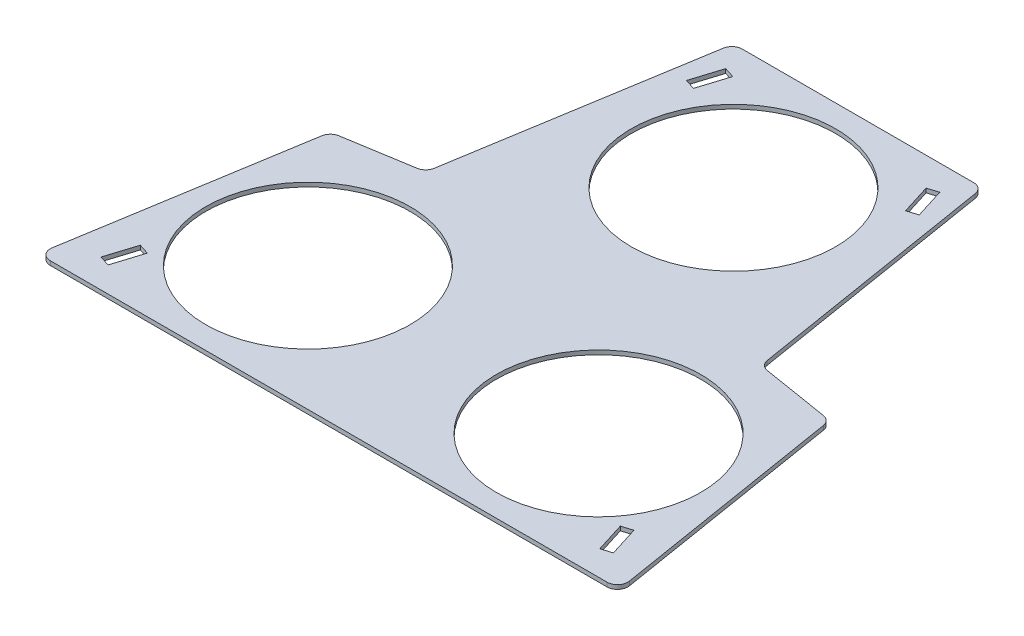
from build123d import *

# Parameters (mm, degrees)
SKETCH1_R           = 49.25
BOSS_EXTRUDE1_DEPTH = 2
CUT_EXTRUDE1_DEPTH  = 5


with BuildPart() as part:
    # Sketch1 → Boss-Extrude1 (new body)
    with BuildSketch(Plane(origin=(0, 0, 0), x_dir=(1, 0, 0), z_dir=(0, 1, 0))):
        with BuildLine():
            Line((-134.118891506, 0), (134.118891506, 0))
            ThreePointArc((134.118891506, 0), (137.928249972, 1.76136015), (139.053747558, 5.804484769))
            Line((139.053747558, 5.804484769), (120.84297072, 117.512705691))
            ThreePointArc((120.84297072, 117.512705691), (119.443648574, 120.243754828), (116.712599437, 121.643076974))
            Line((116.712599437, 121.643076974), (84.336583334, 126.921044874))
            ThreePointArc((84.336583334, 126.921044874), (81.605534197, 128.32036702), (80.206212051, 131.051416157))
            Line((80.206212051, 131.051416157), (60.683956749, 250.804484769))
            ThreePointArc((60.683956749, 250.804484769), (58.987740546, 253.809358466), (55.749100697, 255))
            Line((55.749100697, 255), (-55.749100697, 255))
            ThreePointArc((-55.749100697, 255), (-58.987740546, 253.809358466), (-60.683956749, 250.804484769))
            Line((-60.683956749, 250.804484769), (-80.206212051, 131.051416157))
            ThreePointArc((-80.206212051, 131.051416157), (-81.605534197, 128.32036702), (-84.336583334, 126.921044874))
            Line((-84.336583334, 126.921044874), (-116.712599437, 121.643076974))
            ThreePointArc((-116.712599437, 121.643076974), (-119.443648574, 120.243754828), (-120.84297072, 117.512705691))
            Line((-120.84297072, 117.512705691), (-139.053747558, 5.804484769))
            ThreePointArc((-139.053747558, 5.804484769), (-137.928249972, 1.76136015), (-134.118891506, 0))
        make_face()
        with Locations((0, 195)):
            Circle(SKETCH1_R, mode=Mode.SUBTRACT)
        with Locations((-70, 60)):
            Circle(SKETCH1_R, mode=Mode.SUBTRACT)
        with Locations((70, 60)):
            Circle(SKETCH1_R, mode=Mode.SUBTRACT)
    extrude(amount=BOSS_EXTRUDE1_DEPTH)

    # Sketch2 → Cut-Extrude1 (cut)
    with BuildSketch(Plane(origin=(0, 2, 0), x_dir=(1, 0, 0), z_dir=(0, 1, 0))):
        Polygon((-56.088893707, 228.423441568), (-51.568858582, 242.831053531), (-46.559589522, 241.259518139), (-51.079624647, 226.851906177), align=None)
        Polygon((-118.431141418, 12.168946469), (-113.911106293, 26.576558432), (-118.920375353, 28.148093823), (-123.440410478, 13.740481861), align=None)
        Polygon((123.440410478, 13.740481861), (118.920375353, 28.148093823), (113.911106293, 26.576558432), (118.431141418, 12.168946469), align=None)
        Polygon((51.079624647, 226.851906177), (46.559589522, 241.259518139), (51.568858582, 242.831053531), (56.088893707, 228.423441568), align=None)
    extrude(amount=-CUT_EXTRUDE1_DEPTH, mode=Mode.SUBTRACT)


solid = part.part
